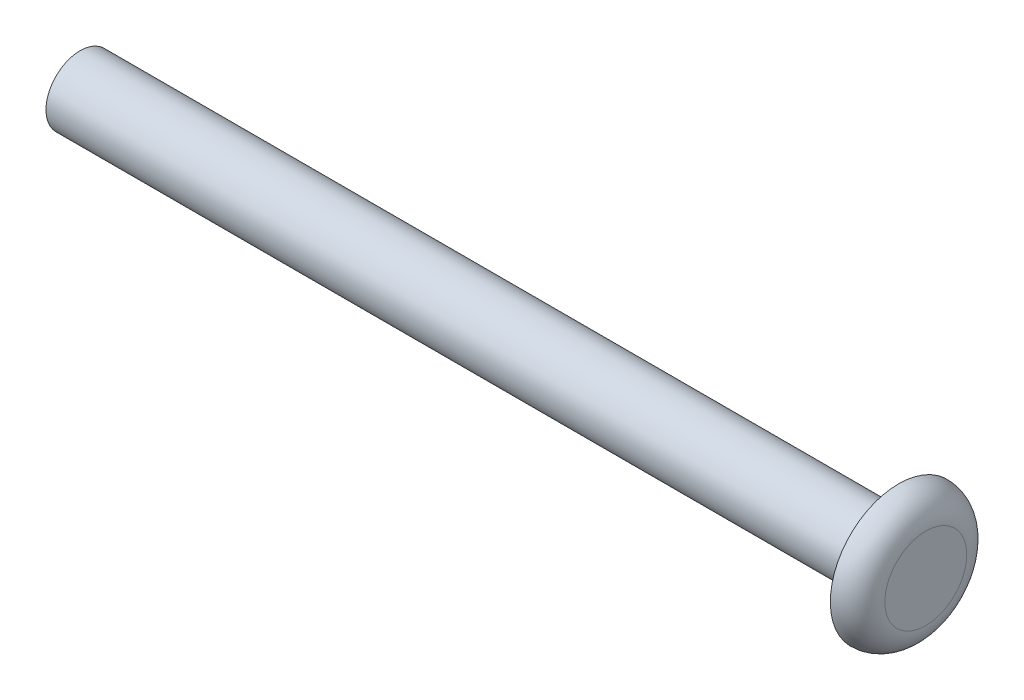
from build123d import *


with BuildPart() as part:
    # Sketch1 → Revolve1 (revolve)
    with BuildSketch(Plane.XY):
        with BuildLine():
            Line((0, 0), (-78.74, 0))
            Line((-78.74, 0), (-78.74, 3.175))
            Line((-78.74, 3.175), (-2.54, 3.175))
            Line((-2.54, 3.175), (-2.54, 6.35))
            ThreePointArc((-2.54, 6.35), (-0.743948776, 5.606051224), (0, 3.81))
            Line((0, 3.81), (0, 0))
        make_face()
    revolve(axis=Axis((0, 0, 0), (-1, 0, 0)))


solid = part.part
